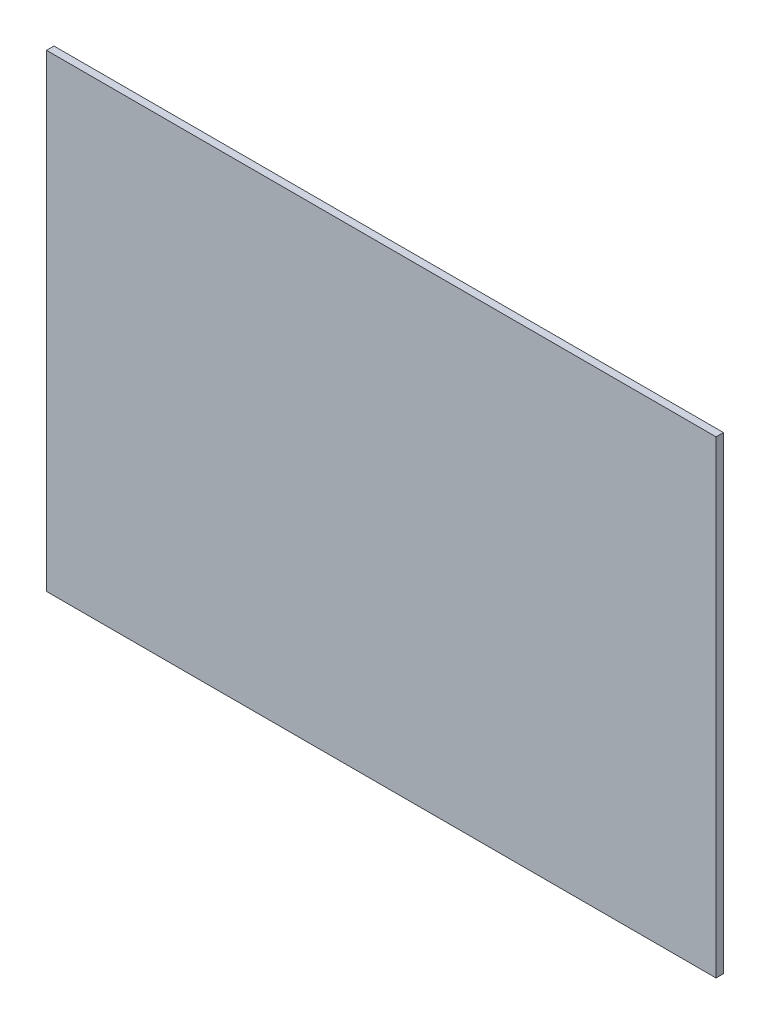
from build123d import *

# Parameters (mm, degrees)
ESQUISSE1_W        = 180
ESQUISSE1_H        = 126
BOSS_EXTRU_1_DEPTH = 2


with BuildPart() as part:
    # Esquisse1 → Boss.-Extru.1 (new body)
    with BuildSketch(Plane.XY):
        with Locations((90, 63)):
            Rectangle(ESQUISSE1_W, ESQUISSE1_H)
    extrude(amount=BOSS_EXTRU_1_DEPTH)


solid = part.part
